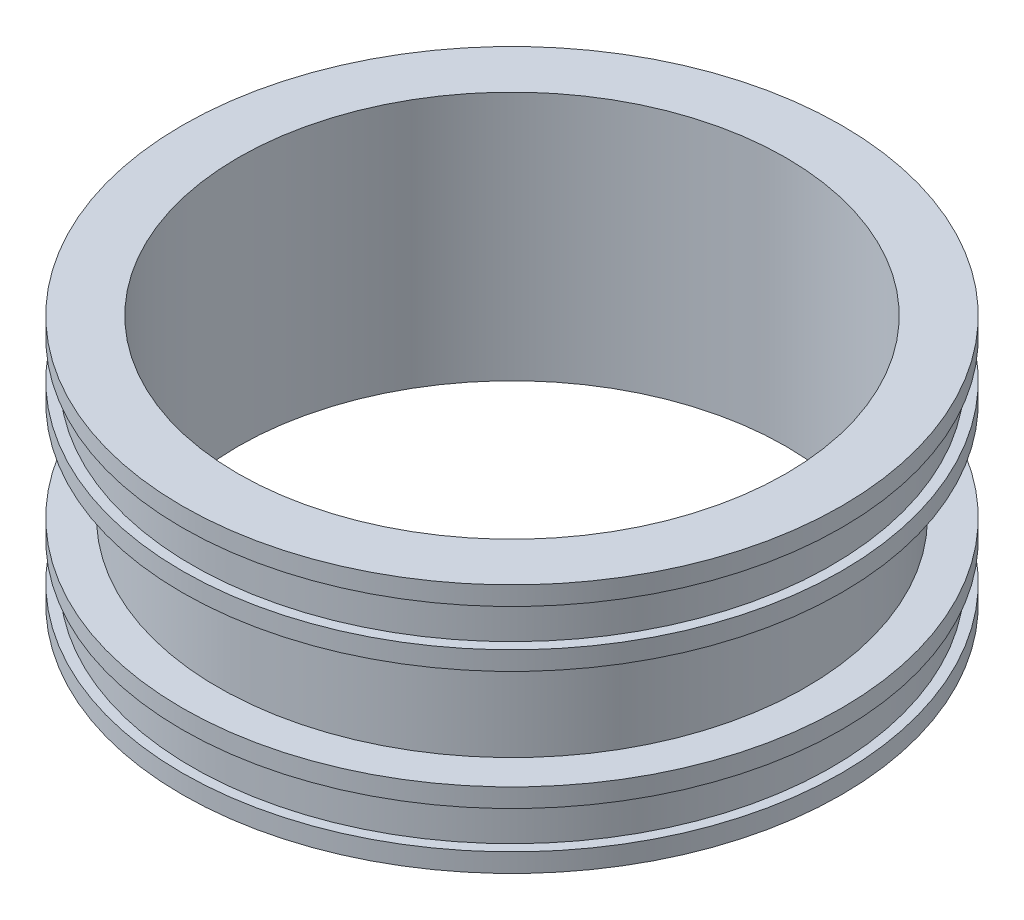
from build123d import *


with BuildPart() as part:
    # Esboço1 → Revolução1 (revolve)
    with BuildSketch(Plane.XY):
        Polygon((109.54, 100), (131.9, 100), (131.9, 92.5), (127.9, 92.5), (127.9, 77.5), (131.9, 77.5), (131.9, 70), (117.54, 70), (117.54, 30), (131.9, 30), (131.9, 22.5), (127.9, 22.5), (127.9, 7.5), (131.9, 7.5), (131.9, 0), (109.54, 0), align=None)
    revolve(axis=Axis((0, 0, 0), (0, 1, 0)))


solid = part.part
